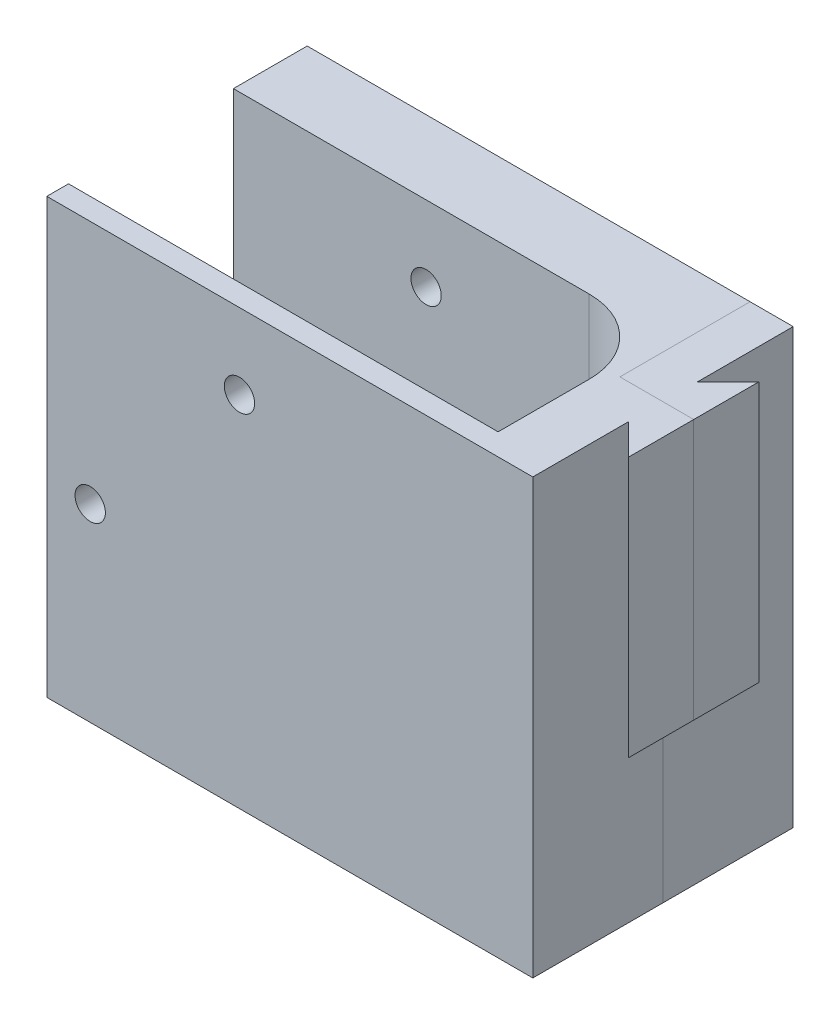
from build123d import *

# Parameters (mm, degrees)
SKETCH1_W              = 56
SKETCH1_H              = 50
BOSS_EXTRUDE1_DEPTH    = 30
SKETCH4_R              = 1.75
CUT_EXTRUDE2_DEPTH     = 81.845531726
CUT_EXTRUDE3_DEPTH     = 81.845531726
BOSS_EXTRUDE2_DEPTH    = 30
SPLIT1_SURFACE_1_BACK  = 84.334
SPLIT1_SURFACE_1_DEPTH = 168.668
SPLIT1_SURFACE_2_BACK  = 84.334
SPLIT1_SURFACE_2_DEPTH = 168.668


with BuildPart() as part:
    # Sketch1 → Boss-Extrude1 (new body)
    with BuildSketch(Plane.XY):
        with Locations((28, 25)):
            Rectangle(SKETCH1_W, SKETCH1_H)
    extrude(amount=BOSS_EXTRUDE1_DEPTH)

    # Sketch4 → Cut-Extrude2 (cut, through all)
    with BuildSketch(Plane(origin=(0, 0, 0), x_dir=(-1, 0, 0), z_dir=(0, 0, -1))):
        with Locations((-5, 21.8)):
            Circle(SKETCH4_R)
        with Locations((-22.2, 41.3)):
            Circle(SKETCH4_R)
    extrude(amount=-CUT_EXTRUDE2_DEPTH, mode=Mode.SUBTRACT)

    # Sketch5 → Cut-Extrude3 (cut, through all)
    with BuildSketch(Plane(origin=(0, 50, 0), x_dir=(1, 0, 0), z_dir=(0, 1, 0))):
        with BuildLine():
            Line((49.5, -17), (49.5, -27.5))
            Line((49.5, -27.5), (0, -27.5))
            Line((0, -27.5), (0, -8.5))
            Line((0, -8.5), (41, -8.5))
            ThreePointArc((41, -8.5), (47.01040764, -10.98959236), (49.5, -17))
        make_face()
    extrude(amount=-CUT_EXTRUDE3_DEPTH, mode=Mode.SUBTRACT)

    # Sketch7 → Boss-Extrude2 (add)
    with BuildSketch(Plane(origin=(0, 50, 0), x_dir=(1, 0, 0), z_dir=(0, 1, 0))):
        Polygon((59.535533906, -7.5), (59.535533906, -22.5), (56, -18.964466094), (55, -18.964466094), (55, -11.035533906), (56, -11.035533906), align=None)
    extrude(amount=-BOSS_EXTRUDE2_DEPTH)


with BuildPart() as body_2:
    # Split1: the piece behind the surface
    add(part.part)
    # Split1 surface: a surface, the sketch's curves swept straight by 168.668 mm
    with BuildLine(Plane(origin=(0, 50, 0), x_dir=(1, 0, 0), z_dir=(0, 1, 0)).offset(-SPLIT1_SURFACE_1_BACK), mode=Mode.PRIVATE) as split1_surface_1_path:
        Line((71.035533906, -15), (51.035533906, -15))
        Line((51.035533906, -15), (51.035533906, 5))
        Line((51.035533906, 5), (71.035533906, 5))
        Line((71.035533906, 5), (71.035533906, -15))
    split1_surface_1 = Shell.extrude(split1_surface_1_path.wire(), (0 * SPLIT1_SURFACE_1_DEPTH, 1 * SPLIT1_SURFACE_1_DEPTH, 0 * SPLIT1_SURFACE_1_DEPTH))
    split(bisect_by=split1_surface_1, keep=Keep.BOTTOM)


with BuildPart() as part_1:
    add(part.part)

    # Split1: split by a surface, the side it looks to stays
    # Split1 surface: a surface, the sketch's curves swept straight by 168.668 mm
    with BuildLine(Plane(origin=(0, 50, 0), x_dir=(1, 0, 0), z_dir=(0, 1, 0)).offset(-SPLIT1_SURFACE_2_BACK), mode=Mode.PRIVATE) as split1_surface_2_path:
        Line((71.035533906, -15), (51.035533906, -15))
        Line((51.035533906, -15), (51.035533906, 5))
        Line((51.035533906, 5), (71.035533906, 5))
        Line((71.035533906, 5), (71.035533906, -15))
    split1_surface_2 = Shell.extrude(split1_surface_2_path.wire(), (0 * SPLIT1_SURFACE_2_DEPTH, 1 * SPLIT1_SURFACE_2_DEPTH, 0 * SPLIT1_SURFACE_2_DEPTH))
    split(bisect_by=split1_surface_2, keep=Keep.TOP)


solid = Compound([body_2.part, part_1.part])
